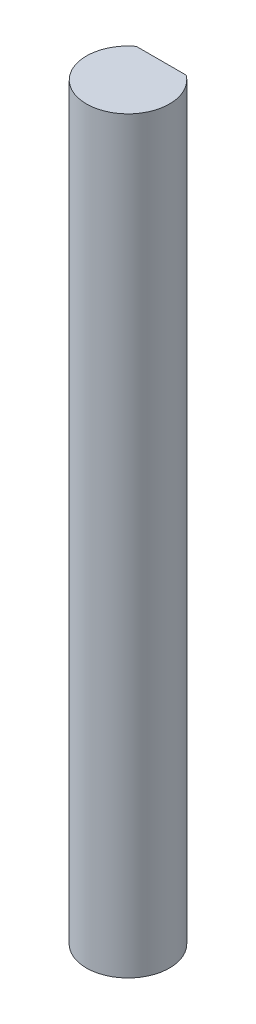
from build123d import *

# Parameters (mm, degrees)
BOSS_EXTRUDE1_DEPTH = 57.15


with BuildPart() as part:
    # Sketch1 → Boss-Extrude1 (new body)
    with BuildSketch(Plane(origin=(0, 0, 0), x_dir=(1, 0, 0), z_dir=(0, 1, 0))):
        with BuildLine():
            Line((-1.905, 2.54), (1.905, 2.54))
            ThreePointArc((1.905, 2.54), (0, -3.175), (-1.905, 2.54))
        make_face()
    extrude(amount=BOSS_EXTRUDE1_DEPTH)


solid = part.part
